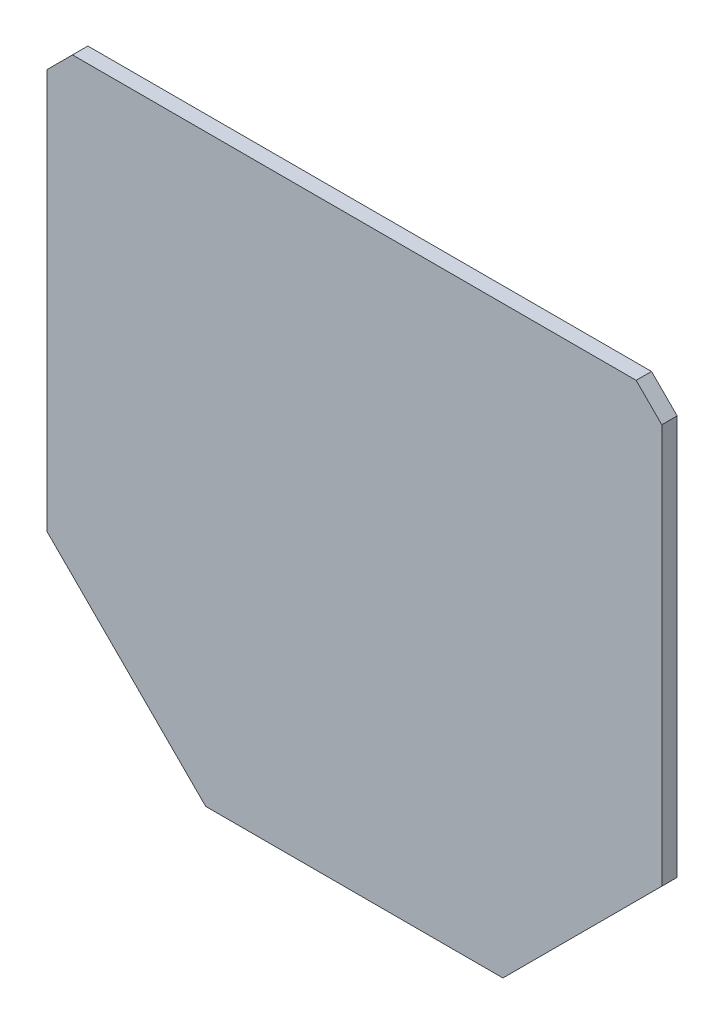
from build123d import *

# Parameters (mm, degrees)
BOSS_EXTRUDE1_DEPTH = 1.5


with BuildPart() as part:
    # Sketch1 → Boss-Extrude1 (new body)
    with BuildSketch(Plane.XY):
        Polygon((0, 22), (-27.497474683, 22), (-30, 19.497474683), (-30, 0), (-30, -19.497474683), (-14.497474683, -35), (14.497474683, -35), (30, -19.497474683), (30, 0), (30, 19.497474683), (27.497474683, 22), align=None)
    extrude(amount=BOSS_EXTRUDE1_DEPTH)


solid = part.part
